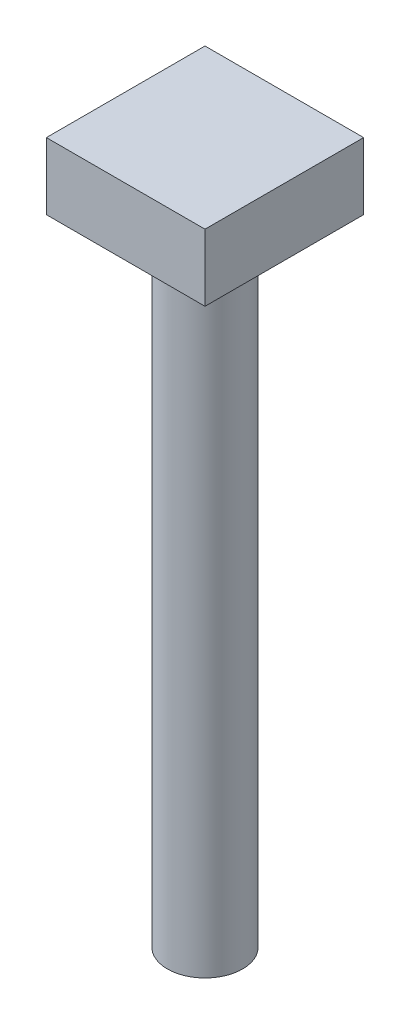
from build123d import *

# Parameters (mm, degrees)
SKETCH3_W           = 19
SKETCH3_H           = 19
BOSS_EXTRUDE1_DEPTH = 8
SKETCH4_R           = 4.5
BOSS_EXTRUDE2_DEPTH = 76


with BuildPart() as part:
    # Sketch3 → Boss-Extrude1 (new body)
    with BuildSketch(Plane(origin=(0, 0, 0), x_dir=(1, 0, 0), z_dir=(0, 1, 0))):
        Rectangle(SKETCH3_W, SKETCH3_H)
    extrude(amount=BOSS_EXTRUDE1_DEPTH)

    # Sketch4 → Boss-Extrude2 (add)
    with BuildSketch(Plane(origin=(0, 0, 0), x_dir=(1, 0, 0), z_dir=(0, 1, 0))):
        with Locations(Location((0, 0, 0), (0, 0, 270))):  # turned: the seam where the file's is
            Circle(SKETCH4_R)
    extrude(amount=-BOSS_EXTRUDE2_DEPTH)


solid = part.part
